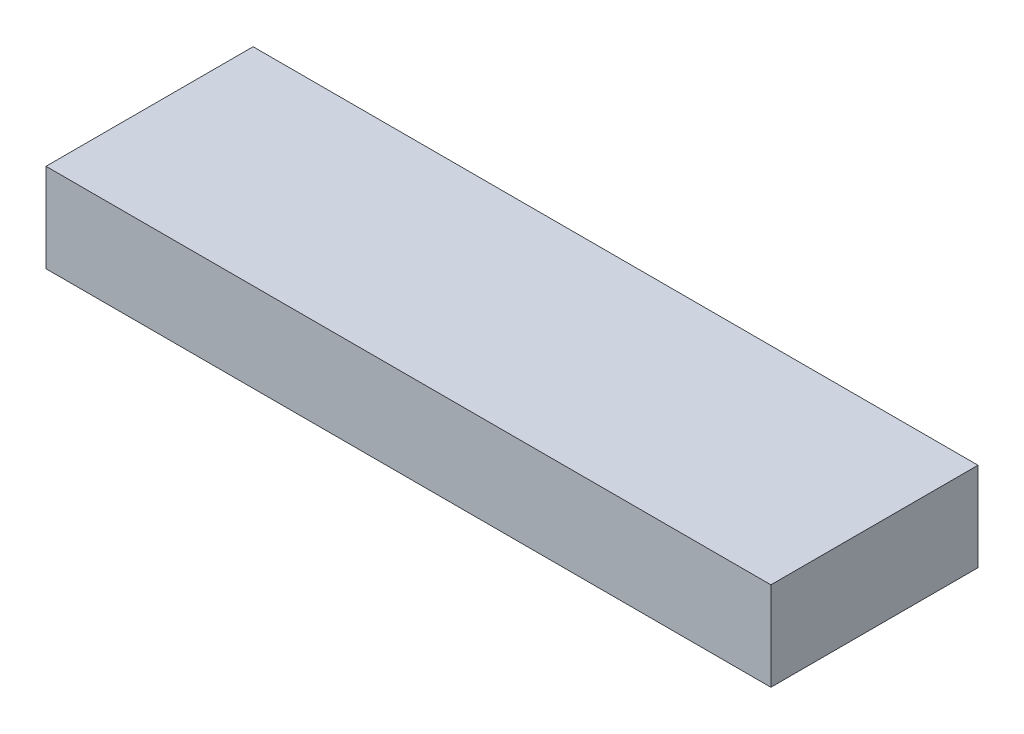
from build123d import *

# Parameters (mm, degrees)
SKETCH1_W           = 311.15
SKETCH1_H           = 88.9
BOSS_EXTRUDE1_DEPTH = 38.1


with BuildPart() as part:
    # Sketch1 → Boss-Extrude1 (new body)
    with BuildSketch(Plane(origin=(0, 0, 0), x_dir=(1, 0, 0), z_dir=(0, 1, 0))):
        with Locations((155.575, -44.45)):
            Rectangle(SKETCH1_W, SKETCH1_H)
    extrude(amount=BOSS_EXTRUDE1_DEPTH)


solid = part.part
